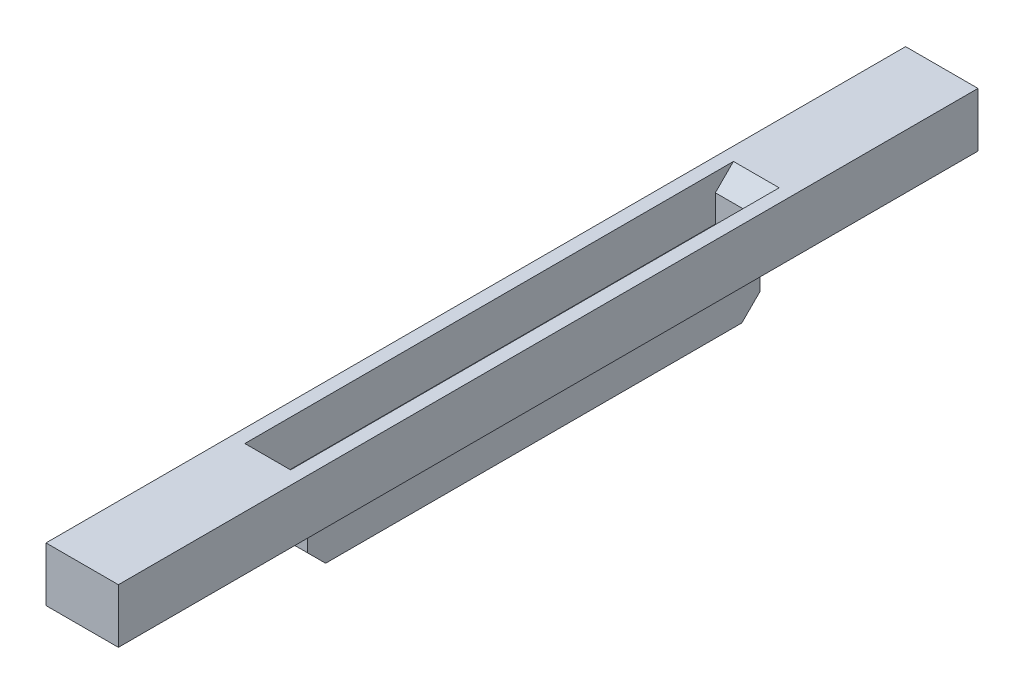
from build123d import *

# Parameters (mm, degrees)
SKETCH1_W           = 8
SKETCH1_H           = 95
SKETCH1_W_2         = 5.05
SKETCH1_H_2         = 50
BOSS_EXTRUDE1_DEPTH = 5
SKETCH1_2_W         = 8
SKETCH1_2_H         = 95
BOSS_EXTRUDE2_DEPTH = 1
SKETCH2_W           = 4.8
SKETCH2_H           = 50
BOSS_EXTRUDE3_DEPTH = 5
CHAMFER2_SIZE       = 2


with BuildPart() as part:
    # Sketch1 → Boss-Extrude1 (new body)
    with BuildSketch(Plane(origin=(0, 0, 0), x_dir=(1, 0, 0), z_dir=(0, 1, 0))):
        Rectangle(SKETCH1_W, SKETCH1_H)
        Rectangle(SKETCH1_W_2, SKETCH1_H_2, mode=Mode.SUBTRACT)
    extrude(amount=BOSS_EXTRUDE1_DEPTH)

    # Sketch1_2 → Boss-Extrude2 (add)
    with BuildSketch(Plane(origin=(0, 0, 0), x_dir=(1, 0, 0), z_dir=(0, 1, 0))):
        Rectangle(SKETCH1_2_W, SKETCH1_2_H)
    extrude(amount=-BOSS_EXTRUDE2_DEPTH)

    # Sketch2 → Boss-Extrude3 (add)
    with BuildSketch(Plane.XZ.offset(1)):
        Rectangle(SKETCH2_W, SKETCH2_H)
    extrude(amount=BOSS_EXTRUDE3_DEPTH)

    # Chamfer2
    chamfer2_edges = [part.edges().sort_by_distance(p)[0] for p in [
        (0, -6, -25),
        (0, -6, 25),
        (0, 5, -25),
        (0, 5, 25),
    ]]
    chamfer(chamfer2_edges, length=CHAMFER2_SIZE)


solid = part.part
